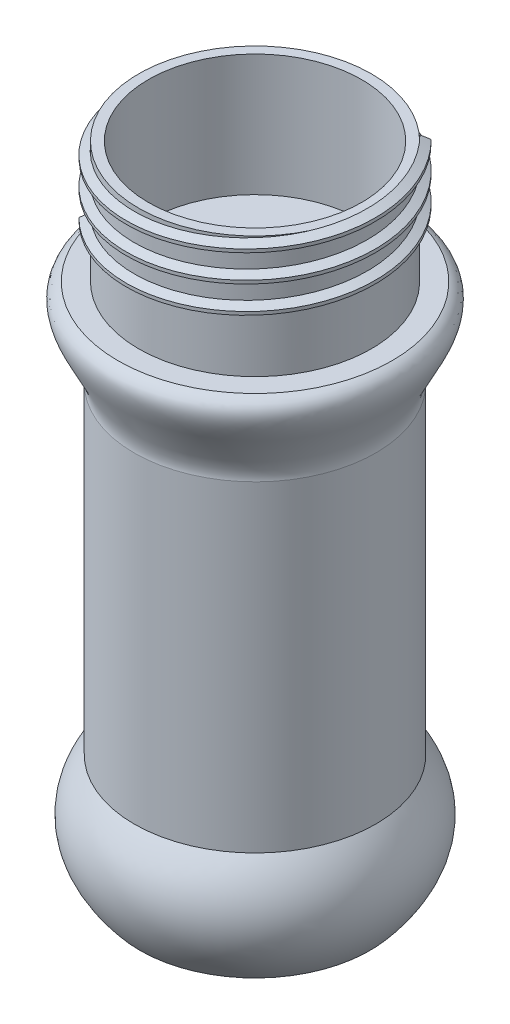
from build123d import *

# Parameters (mm, degrees)
SKETCH_3_R          = 17.85
EXTRUDE_1_DEPTH     = 47.5
SKETCH_5_R          = 17.2
SKETCH_5_R_2        = 15.75
EXTRUDE_2_DEPTH     = 18
SWEEP_6_PITCH       = 4
SWEEP_6_HEIGHT      = 10
SWEEP_6_RADIUS      = 17.2
SWEEP_6_START_ANGLE = 45


with BuildPart() as part:
    # По траектории5: sweep along a path in Эскиз1
    with BuildLine(Plane(origin=(0, 0, 0), x_dir=(1, 0, 0), z_dir=(0, 1, 0))) as sweep_5_path:
        CenterArc((0, 0), 20.25, 0, 360)
    # Эскиз2 → По траектории5 (sweep)
    with BuildSketch(Plane(origin=(0, 0, 20.25), x_dir=(0, 0, -1), z_dir=(1, 0, 0))):
        with BuildLine():
            Line((20.25, -2.884804654), (20.25, 13.715195346))
            Line((20.25, 13.715195346), (2.4, 13.715195346))
            add(Edge.make_bspline(
                [(3.25, -2.884804654), (-4.140339113, 5.721368346), (2.4, 13.715195346)],
                knots=[0, 0, 0, 1, 1, 1], degree=2))
            Line((3.25, -2.884804654), (20.25, -2.884804654))
        make_face()
    sweep(path=sweep_5_path.line)

    # Эскиз3 → Бобышка-Вытянуть1 (add)
    with BuildSketch(Plane(origin=(0, 13.715195346, 0), x_dir=(1, 0, 0), z_dir=(0, 1, 0))):
        Circle(SKETCH_3_R)
    extrude(amount=EXTRUDE_1_DEPTH)

    # Эскиз4 → Повернуть1 (revolve)
    with BuildSketch(Plane(origin=(0, 0, 20.25), x_dir=(0, 0, -1), z_dir=(1, 0, 0))):
        with BuildLine():
            add(Edge.make_bspline(
                [(2.4, 61.215195346), (3.008061282, 65.151641805), (-4.686382265, 72.118473987), (0, 74.215195346)],
                knots=[0, 0, 0, 0, 1, 1, 1, 1], degree=3))
            Line((0, 74.215195346), (20.25, 74.215195346))
            Line((20.25, 74.215195346), (20.25, 61.215195346))
            Line((20.25, 61.215195346), (2.4, 61.215195346))
        make_face()
    revolve(axis=Axis((0, 61.215195346, 0), (0, 1, 0)))

    # Эскиз5 → Бобышка-Вытянуть2 (add)
    with BuildSketch(Plane(origin=(0, 74.215195346, 0), x_dir=(1, 0, 0), z_dir=(0, 1, 0))):
        Circle(SKETCH_5_R)
        Circle(SKETCH_5_R_2, mode=Mode.SUBTRACT)
    extrude(amount=EXTRUDE_2_DEPTH)

    # По траектории6: sweep along a helix
    with BuildLine() as sweep_6_path:
        add(Helix(SWEEP_6_PITCH, SWEEP_6_HEIGHT, SWEEP_6_RADIUS, center=(0, 92.215195346, 0), direction=(0, -1, 0), mode=Mode.PRIVATE).rotate(Axis((0, 92.215195346, 0), (0, -1, 0)), SWEEP_6_START_ANGLE))
    # Эскиз9 → По траектории6 (sweep)
    with BuildSketch(Plane(origin=(12.162236636, 92.215195346, -12.162236636), x_dir=(0.705651254, -0.037044276, -0.707590298), z_dir=(0.706622929, -0.036987451, 0.706622929))):
        Polygon((0, 0.803706964), (0, -0.803706964), (1.2, -0.25), (1.2, 0.25), align=None)
    sweep(path=sweep_6_path.line, is_frenet=True)


solid = part.part
